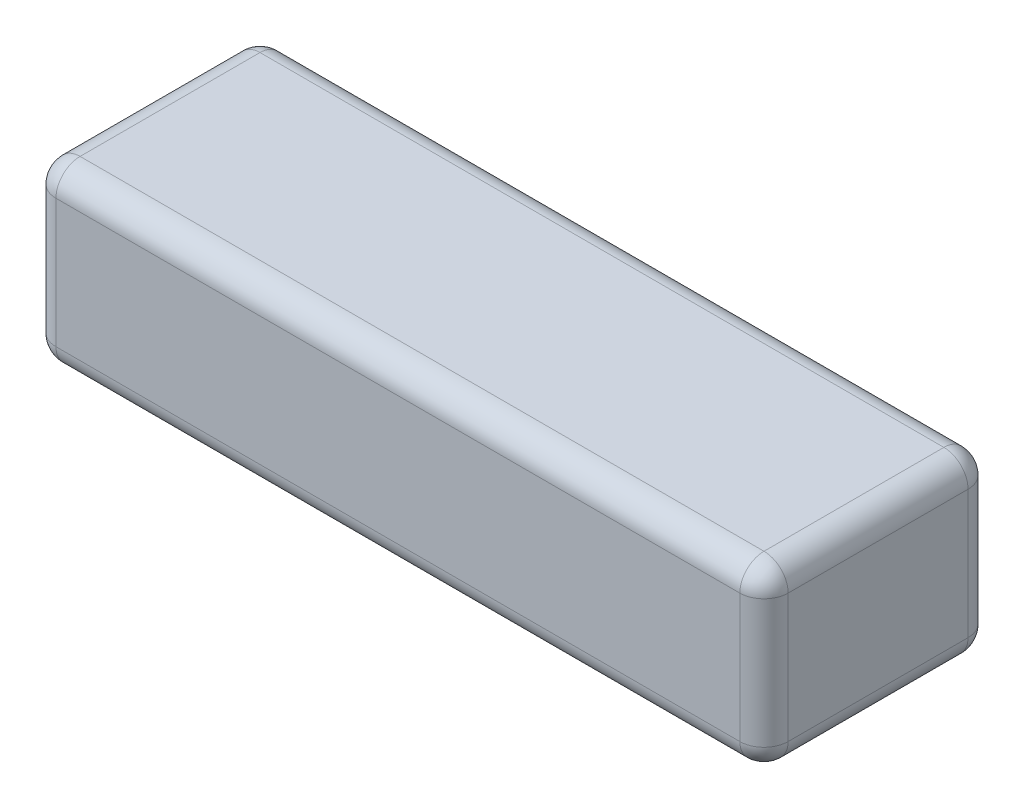
from build123d import *

# Parameters (mm, degrees)
SKETCH1_W           = 154
SKETCH1_H           = 48
BOSS_EXTRUDE1_DEPTH = 37.2
FILLET1_R           = 5.08


with BuildPart() as part:
    # Sketch1 → Boss-Extrude1 (new body)
    with BuildSketch(Plane(origin=(0, 0, 0), x_dir=(1, 0, 0), z_dir=(0, 1, 0))):
        Rectangle(SKETCH1_W, SKETCH1_H)
    extrude(amount=BOSS_EXTRUDE1_DEPTH)

    # Fillet1
    fillet1_edges = [part.edges().sort_by_distance(p)[0] for p in [
        (-77, 37.2, 0),
        (0, 37.2, 24),
        (77, 37.2, 0),
        (0, 0, 24),
        (-77, 0, 0),
        (0, 0, -24),
        (77, 0, 0),
        (77, 18.6, 24),
        (-77, 18.6, 24),
        (-77, 18.6, -24),
        (77, 18.6, -24),
        (0, 37.2, -24),
    ]]
    fillet(fillet1_edges, radius=FILLET1_R)


solid = part.part
